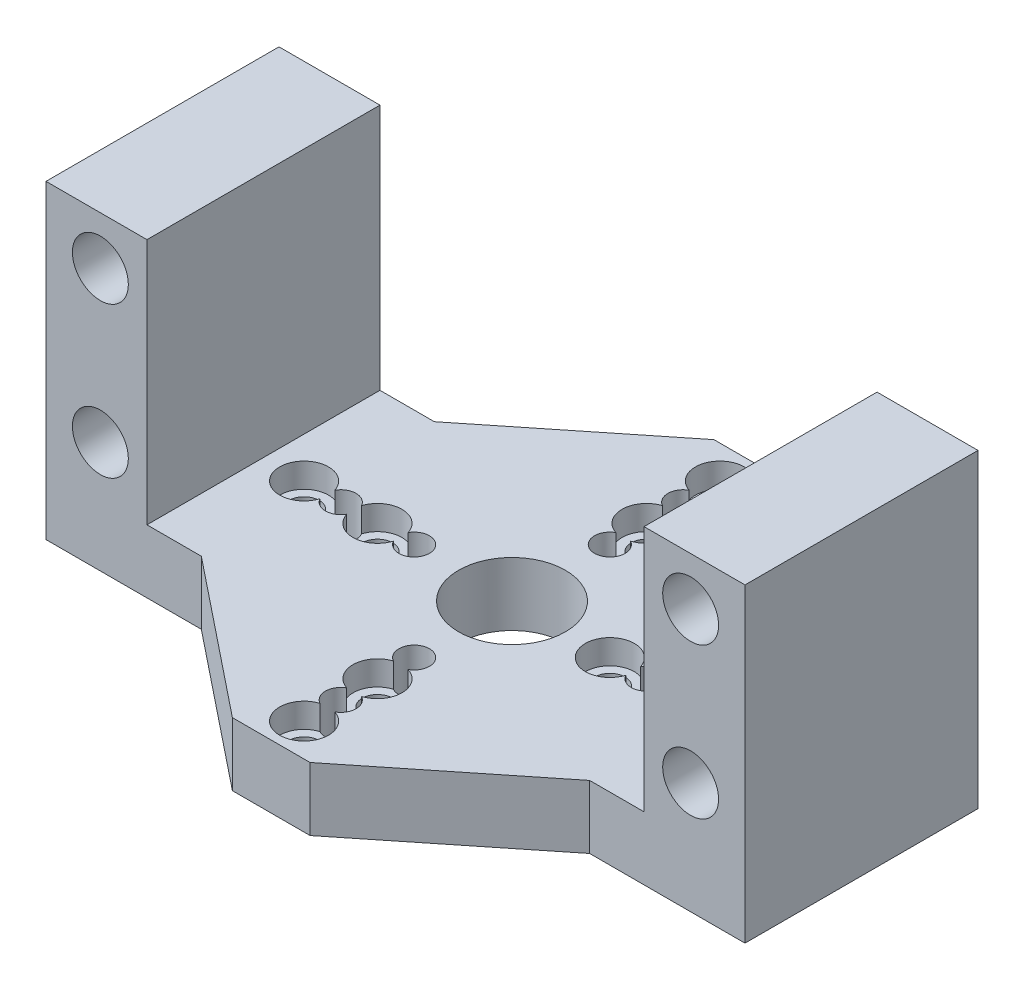
from build123d import *

# Parameters (mm, degrees)
SKETCH1_R           = 2.286
BOSS_EXTRUDE1_DEPTH = 19.05
BOSS_EXTRUDE2_DEPTH = 5.175
SKETCH2_R           = 1.25
SKETCH2_R_2         = 4.365625
CUT_EXTRUDE1_DEPTH  = 5.175
SKETCH4_R           = 2
CUT_EXTRUDE2_DEPTH  = 2


with BuildPart() as part:
    # Sketch1 → Boss-Extrude1 (new body)
    with BuildSketch(Plane.XY):
        Polygon((8.255, 25.368), (8.255, 5.175), (48.895, 5.175), (48.895, 25.368), (57.15, 25.368), (57.15, 0), (0, 0), (0, 25.368), align=None)
        with Locations((4.445, 21.431)):
            Circle(SKETCH1_R, mode=Mode.SUBTRACT)
        with Locations((4.445, 9.112)):
            Circle(SKETCH1_R, mode=Mode.SUBTRACT)
        with Locations((52.705, 9.112)):
            Circle(SKETCH1_R, mode=Mode.SUBTRACT)
        with Locations((52.705, 21.431)):
            Circle(SKETCH1_R, mode=Mode.SUBTRACT)
    extrude(amount=BOSS_EXTRUDE1_DEPTH)

    # Sketch3 → Boss-Extrude2 (add)
    with BuildSketch(Plane.XZ):
        Polygon((25.4, 29.21), (31.75, 29.21), (44.45, 19.05), (44.45, 0), (31.75, -10.16), (25.4, -10.16), (12.7, 0), (12.7, 19.05), align=None)
    extrude(amount=-BOSS_EXTRUDE2_DEPTH)

    # Sketch2 → Cut-Extrude1 (cut)
    with BuildSketch(Plane.XZ):
        with Locations((36.5750114, 9.525)):
            Circle(SKETCH2_R)
        with Locations((39.5750054, 9.525)):
            Circle(SKETCH2_R)
        with Locations((42.5749994, 9.525)):
            Circle(SKETCH2_R)
        with Locations((45.5749934, 9.525)):
            Circle(SKETCH2_R)
        with Locations((28.575, 1.5249886)):
            Circle(SKETCH2_R)
        with Locations((28.575, -1.4750054)):
            Circle(SKETCH2_R)
        with Locations((28.575, -4.4749994)):
            Circle(SKETCH2_R)
        with Locations((28.575, -7.4749934)):
            Circle(SKETCH2_R)
        with Locations((20.5749886, 9.525)):
            Circle(SKETCH2_R)
        with Locations((17.5749946, 9.525)):
            Circle(SKETCH2_R)
        with Locations((14.5750006, 9.525)):
            Circle(SKETCH2_R)
        with Locations((11.5750066, 9.525)):
            Circle(SKETCH2_R)
        with Locations((28.575, 17.5250114)):
            Circle(SKETCH2_R)
        with Locations((28.575, 20.5250054)):
            Circle(SKETCH2_R)
        with Locations((28.575, 23.5249994)):
            Circle(SKETCH2_R)
        with Locations((28.575, 26.5249934)):
            Circle(SKETCH2_R)
        with Locations((28.575, 9.525)):
            Circle(SKETCH2_R_2)
    extrude(amount=-CUT_EXTRUDE1_DEPTH, mode=Mode.SUBTRACT)

    # Sketch4 → Cut-Extrude2 (cut)
    with BuildSketch(Plane(origin=(0, 5.175, 0), x_dir=(1, 0, 0), z_dir=(0, 1, 0))):
        with Locations((28.575, 1.4750054)):
            Circle(SKETCH4_R)
        with Locations((28.575, 7.4749934)):
            Circle(SKETCH4_R)
        with Locations((11.5750066, -9.525)):
            Circle(SKETCH4_R)
        with Locations((17.5749946, -9.525)):
            Circle(SKETCH4_R)
        with Locations((36.5750114, -9.525)):
            Circle(SKETCH4_R)
        with Locations((28.575, -20.5250054)):
            Circle(SKETCH4_R)
        with Locations((45.5749934, -9.525)):
            Circle(SKETCH4_R)
        with Locations((28.575, -26.5249934)):
            Circle(SKETCH4_R)
    extrude(amount=-CUT_EXTRUDE2_DEPTH, mode=Mode.SUBTRACT)


solid = part.part
